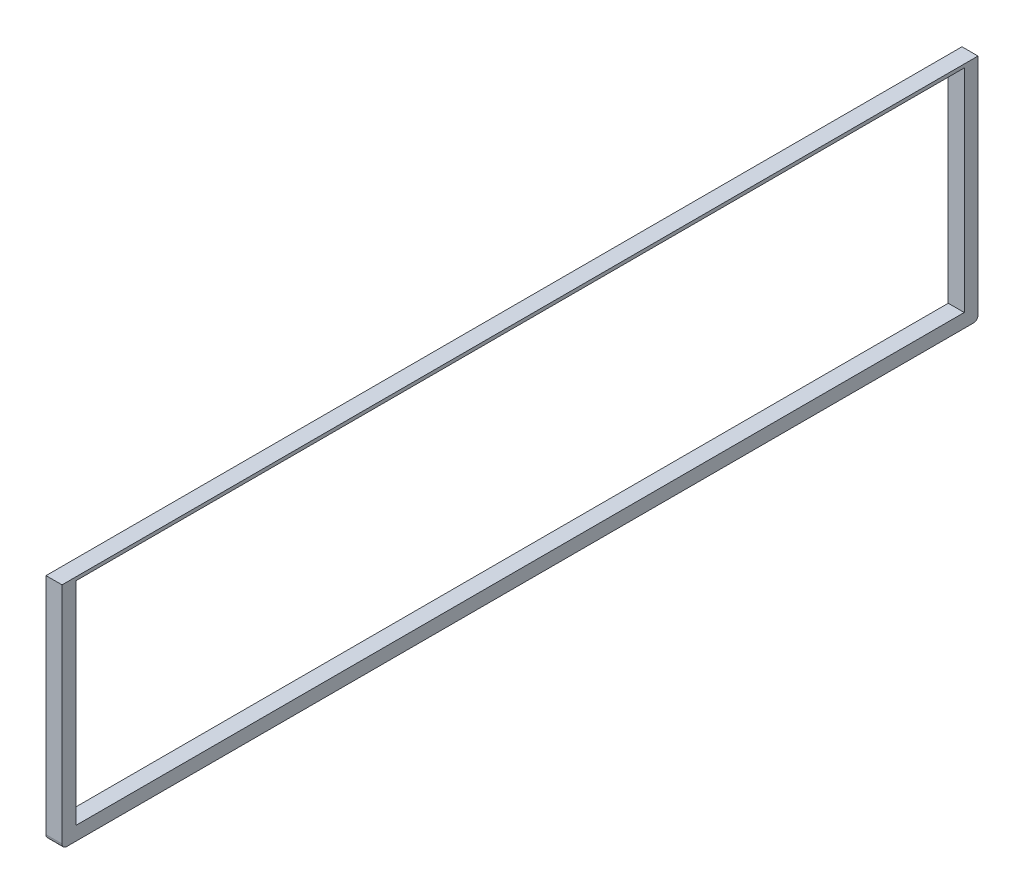
from build123d import *

# Parameters (mm, degrees)
SKETCH1_W           = 2000
SKETCH1_H           = 500
BOSS_EXTRUDE1_DEPTH = 35
SKETCH2_W           = 1940
SKETCH2_H           = 462.5
CUT_EXTRUDE1_DEPTH  = 35
FILLET1_R           = 10


with BuildPart() as part:
    # Sketch1 → Boss-Extrude1 (new body)
    with BuildSketch(Plane(origin=(0, 0, 0), x_dir=(0, 0, -1), z_dir=(1, 0, 0))):
        with Locations((-700.985902425, -1163.463280399)):
            Rectangle(SKETCH1_W, SKETCH1_H)
    extrude(amount=BOSS_EXTRUDE1_DEPTH)

    # Sketch2 → Cut-Extrude1 (cut)
    with BuildSketch(Plane(origin=(35, 0, 0), x_dir=(0, 0, -1), z_dir=(1, 0, 0))):
        with Locations((-700.985902425, -1152.213280399)):
            Rectangle(SKETCH2_W, SKETCH2_H)
    extrude(amount=-CUT_EXTRUDE1_DEPTH, mode=Mode.SUBTRACT)

    # Fillet1
    fillet1_edges = [part.edges().sort_by_distance(p)[0] for p in [
        (17.5, -1413.463280399, -299.014097575),
        (17.5, -1413.463280399, 1700.985902425),
    ]]
    fillet(fillet1_edges, radius=FILLET1_R)


solid = part.part
